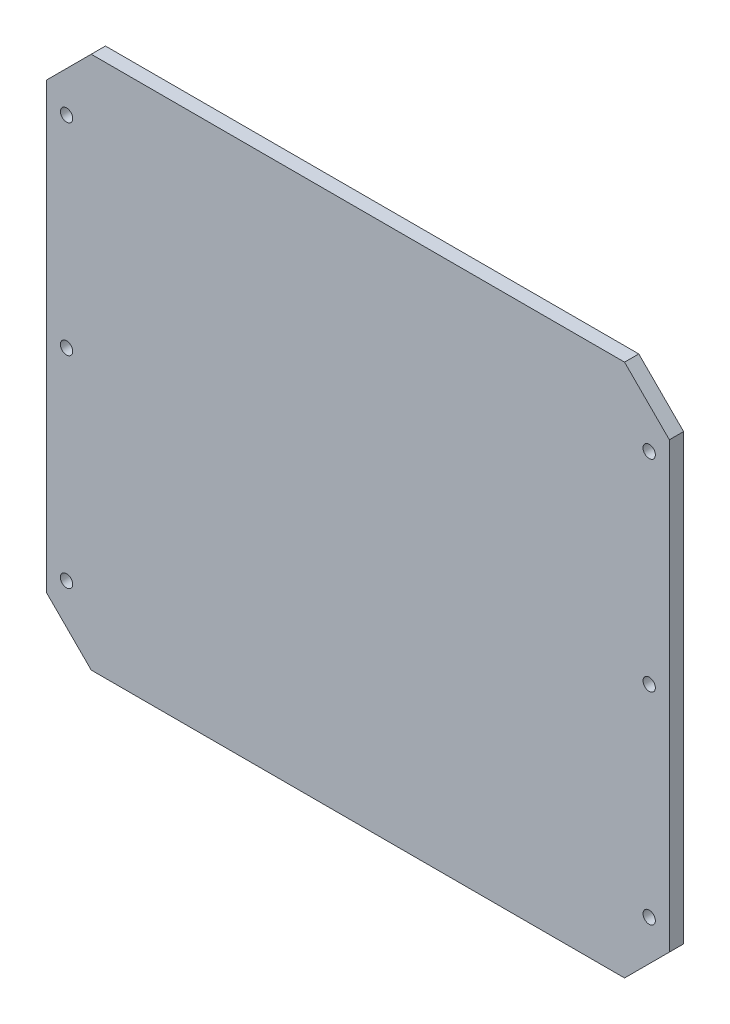
from build123d import *

# Parameters (mm, degrees)
SKETCH1_W           = 278
SKETCH1_H           = 238
BOSS_EXTRUDE1_DEPTH = 6.35
CHAMFER1_SIZE       = 20
SKETCH4_R           = 2.75
CUT_EXTRUDE2_DEPTH  = 76.2


with BuildPart() as part:
    # Sketch1 → Boss-Extrude1 (new body)
    with BuildSketch(Plane.XY):
        Rectangle(SKETCH1_W, SKETCH1_H)
    extrude(amount=BOSS_EXTRUDE1_DEPTH)

    # Chamfer1
    chamfer1_edges = [part.edges().sort_by_distance(p)[0] for p in [
        (-139, 119, 3.175),
        (139, 119, 3.175),
        (139, -119, 3.175),
        (-139, -119, 3.175),
    ]]
    chamfer(chamfer1_edges, length=CHAMFER1_SIZE)

    # Sketch4 → Cut-Extrude2 (cut)
    with BuildSketch(Plane.XY.offset(6.35)):
        with Locations((-130, 90)):
            Circle(SKETCH4_R)
        with Locations((-130, -90)):
            Circle(SKETCH4_R)
        with Locations((-130, 0)):
            Circle(SKETCH4_R)
        with Locations((130, -90)):
            Circle(SKETCH4_R)
        with Locations((130, 0)):
            Circle(SKETCH4_R)
        with Locations((130, 90)):
            Circle(SKETCH4_R)
    extrude(amount=-CUT_EXTRUDE2_DEPTH, mode=Mode.SUBTRACT)


solid = part.part
